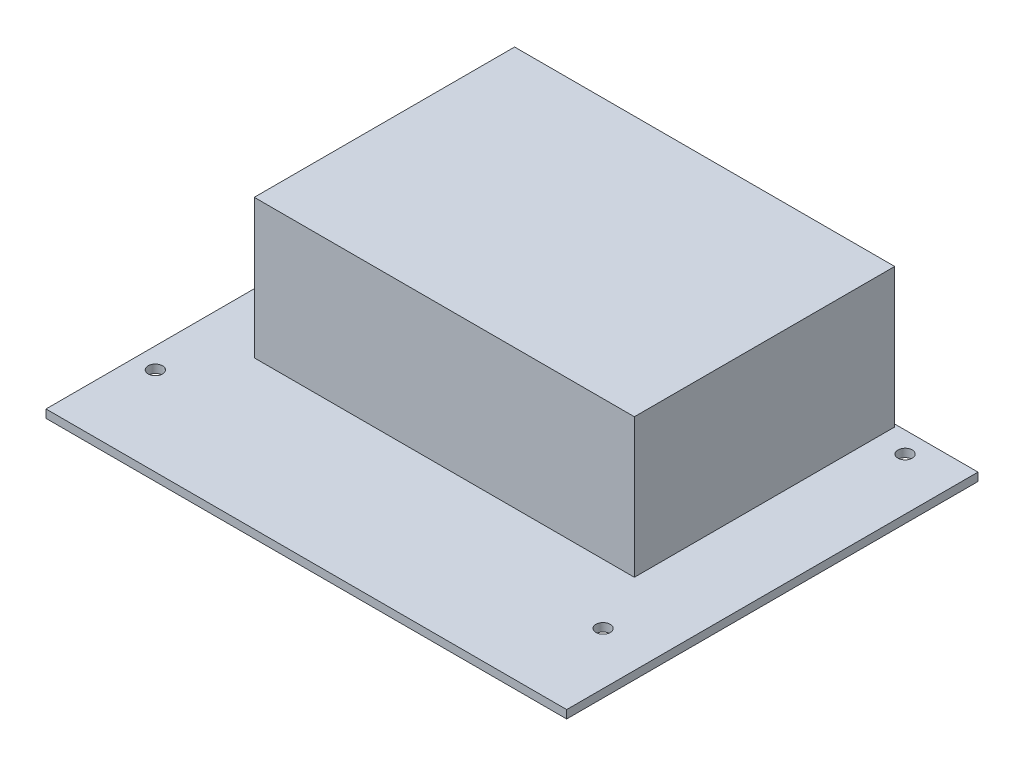
from build123d import *

# Parameters (mm, degrees)
SKETCH1_W           = 100
SKETCH1_H           = 79
SKETCH1_R           = 1.375
BOSS_EXTRUDE1_DEPTH = 1.57
SKETCH2_W           = 73
SKETCH2_H           = 50
BOSS_EXTRUDE2_DEPTH = 26.706


with BuildPart() as part:
    # Sketch1 → Boss-Extrude1 (new body)
    with BuildSketch(Plane(origin=(0, 0, 0), x_dir=(1, 0, 0), z_dir=(0, 1, 0))):
        Rectangle(SKETCH1_W, SKETCH1_H)
        with Locations((-46, 35.5)):
            Circle(SKETCH1_R, mode=Mode.SUBTRACT)
        with Locations((40, 35.5)):
            Circle(SKETCH1_R, mode=Mode.SUBTRACT)
        with Locations((-46, -22.5)):
            Circle(SKETCH1_R, mode=Mode.SUBTRACT)
        with Locations((40, -22.5)):
            Circle(SKETCH1_R, mode=Mode.SUBTRACT)
    extrude(amount=BOSS_EXTRUDE1_DEPTH)

    # Sketch2 → Boss-Extrude2 (add)
    with BuildSketch(Plane(origin=(0, 1.57, 0), x_dir=(1, 0, 0), z_dir=(0, 1, 0))):
        with Locations((-2, 14)):
            Rectangle(SKETCH2_W, SKETCH2_H)
    extrude(amount=BOSS_EXTRUDE2_DEPTH)


solid = part.part
